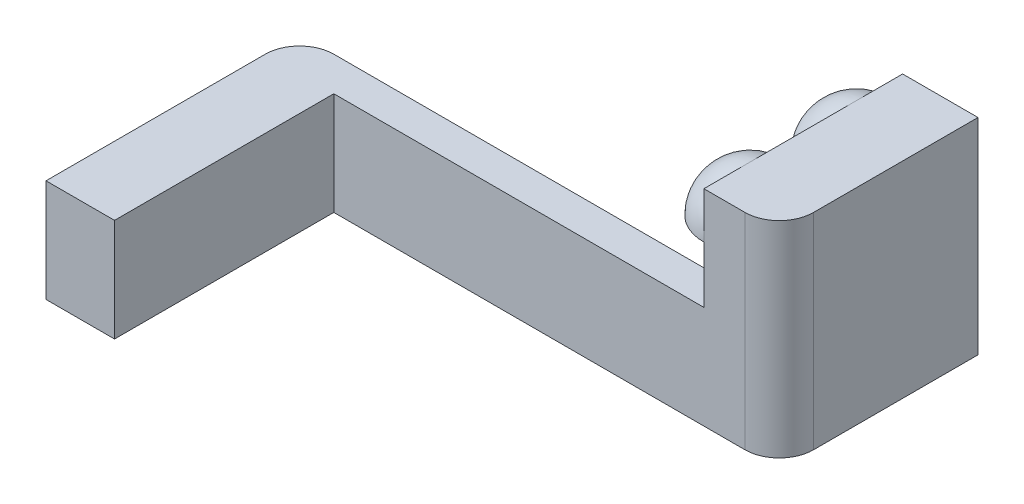
from build123d import *

# Parameters (mm, degrees)
SKETCH1_W                       = 60
SKETCH1_H                       = 15
BOSS_EXTRUDE1_DEPTH             = 5
SKETCH2_W                       = 37
SKETCH2_H                       = 15
BOSS_EXTRUDE2_DEPTH             = 10
FILLET1_R                       = 5
SKETCH3_W                       = 29
SKETCH3_H                       = 30
BOSS_EXTRUDE3_DEPTH             = 5
FILLET2_R                       = 5
BOSS_EXTRUDE6_REACH             = 26
SKETCH8_W                       = 6
SKETCH8_H                       = 30
BOSS_EXTRUDE6_DIRECTION_2_REACH = 39
SKETCH7_W                       = 6
SKETCH7_H                       = 22
CUT_EXTRUDE3_DEPTH              = 11
REVOLVE1_ANGLE                  = 90


with BuildPart() as part:
    # Sketch1 → Boss-Extrude1 (new body)
    with BuildSketch(Plane.XY):
        Rectangle(SKETCH1_W, SKETCH1_H)
    extrude(amount=BOSS_EXTRUDE1_DEPTH)

    # Sketch2 → Boss-Extrude2 (add)
    with BuildSketch(Plane.ZY.offset(30)):
        with Locations((-13.5, 0)):
            Rectangle(SKETCH2_W, SKETCH2_H)
    extrude(amount=BOSS_EXTRUDE2_DEPTH)

    # Fillet1
    fillet1_edges = [part.edges().sort_by_distance(p)[0] for p in [
        (-40, 0, 5),
    ]]
    fillet(fillet1_edges, radius=FILLET1_R)

    # Sketch3 → Boss-Extrude3 (add)
    with BuildSketch(Plane(origin=(30, 0, 0), x_dir=(0, 0, -1), z_dir=(1, 0, 0))):
        with Locations((-14.5, 7.5)):
            Rectangle(SKETCH3_W, SKETCH3_H)
    extrude(amount=BOSS_EXTRUDE3_DEPTH)

    # Fillet2
    fillet2_edges = [part.edges().sort_by_distance(p)[0] for p in [
        (35, 7.5, 0),
    ]]
    fillet(fillet2_edges, radius=FILLET2_R)

    # Boss-Extrude6: up to this face of the body (flat: up to its plane)
    boss_extrude6_end = Plane(part.part.faces().sort_by_distance((32.5, 7.5, 29))[0])
    # Sketch8 → Boss-Extrude6 (add, up to the picked face)
    with BuildSketch(Plane.XY.offset(5), mode=Mode.PRIVATE) as boss_extrude6_sk1:
        with Locations((27, 7.5)):
            Rectangle(SKETCH8_W, SKETCH8_H)
    boss_extrude6_tool1 = split(extrude(boss_extrude6_sk1.sketch, amount=BOSS_EXTRUDE6_REACH, mode=Mode.PRIVATE), bisect_by=boss_extrude6_end, keep=Keep.BOTH, mode=Mode.PRIVATE)
    add(boss_extrude6_tool1.solids().sort_by(Axis((27, 7.5, 5), (0, 0, 1)))[0])

    # Boss-Extrude6 direction 2: up to this face of the body (flat: up to its plane)
    boss_extrude6_direction_2_end = Plane(part.part.faces().sort_by_distance((0, 0, 0))[0])
    # Sketch8 → Boss-Extrude6 direction 2 (add, up to the picked face)
    with BuildSketch(Plane.XY.offset(5), mode=Mode.PRIVATE) as boss_extrude6_direction_2_sk1:
        with Locations((27, 7.5)):
            Rectangle(SKETCH8_W, SKETCH8_H)
    boss_extrude6_direction_2_tool1 = split(extrude(boss_extrude6_direction_2_sk1.sketch, amount=-BOSS_EXTRUDE6_DIRECTION_2_REACH, mode=Mode.PRIVATE), bisect_by=boss_extrude6_direction_2_end, keep=Keep.BOTH, mode=Mode.PRIVATE)
    add(boss_extrude6_direction_2_tool1.solids().sort_by(Axis((27, 7.5, 5), (0, 0, -1)))[0])

    # Sketch7 → Cut-Extrude3 (cut)
    with BuildSketch(Plane.XZ.offset(7.5)):
        with Locations((30, 16)):
            Rectangle(SKETCH7_W, SKETCH7_H)
        with Locations((-35, -16)):
            Rectangle(SKETCH7_W, SKETCH7_H)
    extrude(amount=-CUT_EXTRUDE3_DEPTH, mode=Mode.SUBTRACT)

    # Sketch9 → Revolve1 (revolve)
    with BuildSketch(Plane.ZY.offset(-24)):
        with BuildLine():
            Line((15.5, 15.75), (29, 15.75))
            ThreePointArc((29, 15.75), (22.25, 22.5), (15.5, 15.75))
        make_face()
        with BuildLine():
            ThreePointArc((13.5, 15.75), (6.75, 22.5), (0, 15.75))
            Line((0, 15.75), (13.5, 15.75))
        make_face()
    revolve(axis=Axis((24, 15.75, 0), (0, 0, 1)), revolution_arc=REVOLVE1_ANGLE)


with BuildPart() as body_2:
    # Mirror1: mirrored copy
    add(part.part.mirror(Plane(origin=(-40, 7.5, -32), x_dir=(1, 0, 0), z_dir=(0, 0, 1))))


solid = body_2.part
